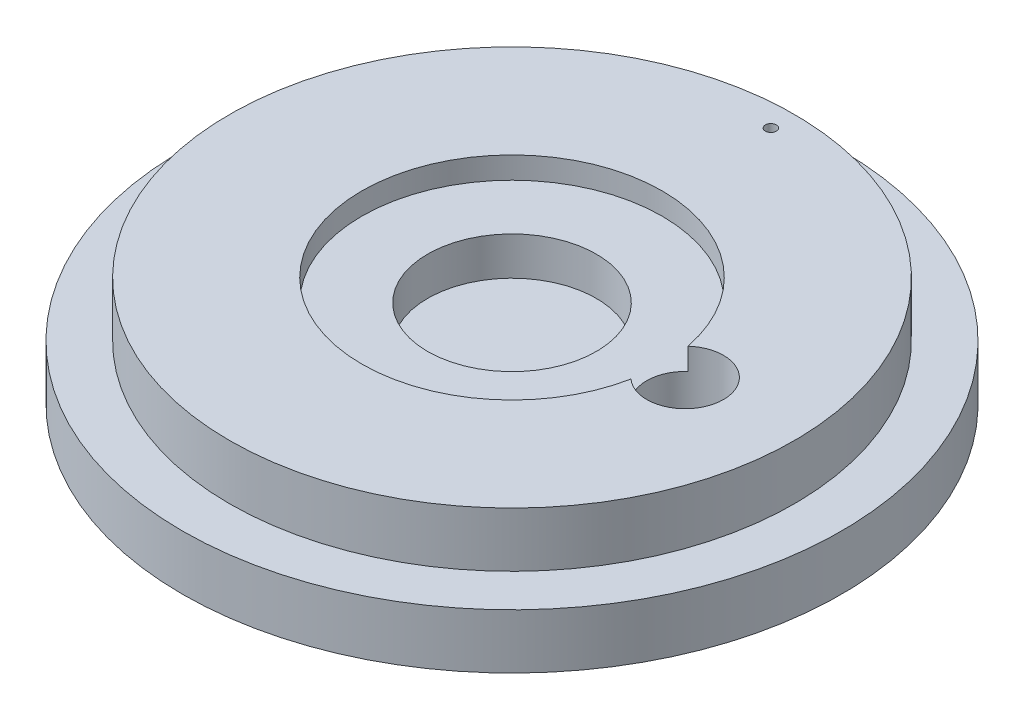
from build123d import *

# Parameters (mm, degrees)
SKETCH2_R          = 3.5
CUT_EXTRUDE1_DEPTH = 10
SKETCH3_R          = 0.5
CUT_EXTRUDE2_DEPTH = 5


with BuildPart() as part:
    # Sketch1 → Revolve1 (revolve)
    with BuildSketch(Plane.XY):
        Polygon((0, 0), (-30.075, 0), (-30.075, 5), (-25.775, 5), (-25.775, 10), (-13.7, 10), (-13.7, 8), (-7.7, 8), (-7.7, 4.5), (0, 4.5), align=None)
    revolve(axis=Axis((0, 4.5, 0), (0, -1, 0)))

    # Sketch2 → Cut-Extrude1 (cut)
    with BuildSketch(Plane(origin=(0, 10, 0), x_dir=(1, 0, 0), z_dir=(0, 1, 0))):
        with Locations((15.8, 0)):
            Circle(SKETCH2_R)
    extrude(amount=-CUT_EXTRUDE1_DEPTH, mode=Mode.SUBTRACT)

    # Sketch3 → Cut-Extrude2 (cut, symmetric)
    with BuildSketch(Plane(origin=(0, 5, 0), x_dir=(1, 0, 0), z_dir=(0, 1, 0))):
        with Locations((0, 23.625)):
            Circle(SKETCH3_R)
    extrude(amount=CUT_EXTRUDE2_DEPTH, both=True, mode=Mode.SUBTRACT)


solid = part.part
